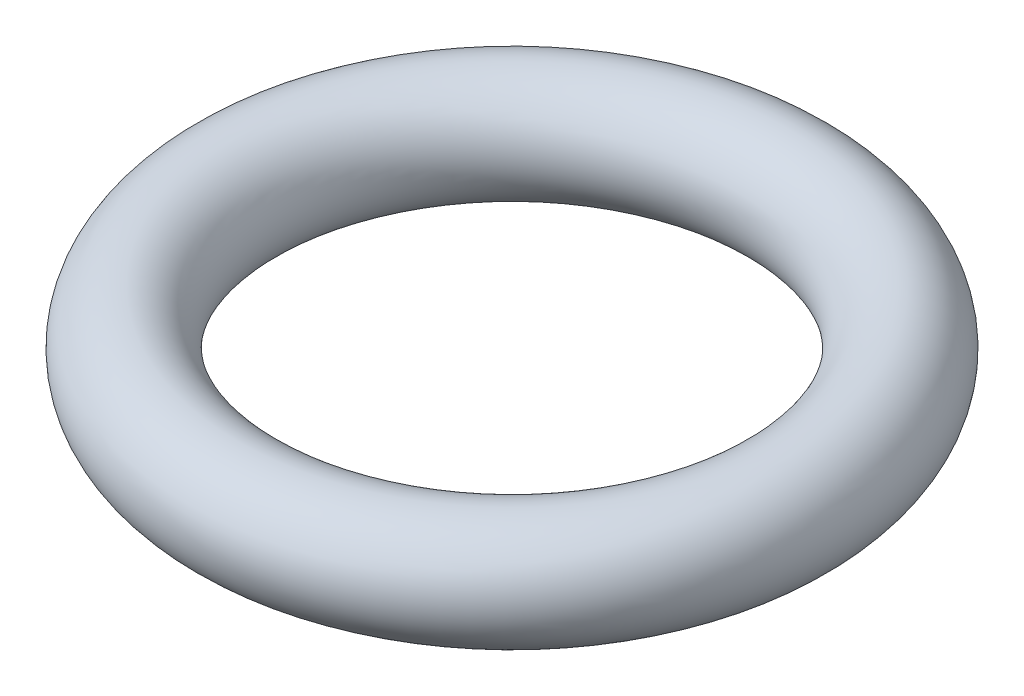
from build123d import *

# Parameters (mm, degrees)
SKETCH1_R = 0.8


with BuildPart() as part:
    # Sketch1 → Revolve1 (revolve)
    with BuildSketch(Plane.XY):
        with Locations((4, 0)):
            Circle(SKETCH1_R)
    revolve(axis=Axis((0, 0, 0), (0, 1, 0)))


solid = part.part
